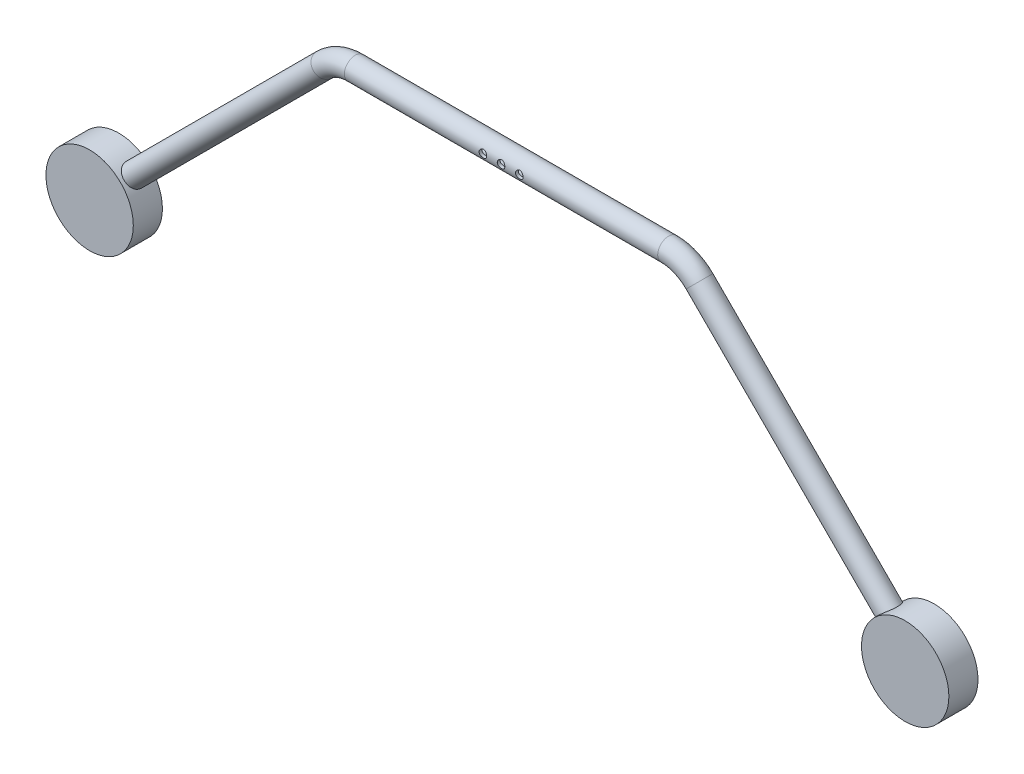
from build123d import *

# Parameters (mm, degrees)
SKETCH1_R                     = 38.1
BOSS_EXTRUDE1_DEPTH           = 25.4
BOSS_EXTRUDE1_2_DEPTH         = 25.4
SWEEP1_PROFILE_R              = 9.525
SHELL1_T                      = -2.54
M6_CLEARANCE_HOLE1_AT_2_COUNT = 2
M6_CLEARANCE_HOLE1_AT_2_PITCH = 31.75


with BuildPart() as part:
    # Sketch1 → Boss-Extrude1 (new body)
    with BuildSketch(Plane.XY):
        with Locations((-355.6, -203.2)):
            Circle(SKETCH1_R)
    extrude(amount=BOSS_EXTRUDE1_DEPTH)


with BuildPart() as body_2:
    # Sketch1 → Boss-Extrude1 2 (new body)
    with BuildSketch(Plane.XY):
        with Locations((355.6, -203.2)):
            Circle(SKETCH1_R)
    extrude(amount=BOSS_EXTRUDE1_2_DEPTH)


with BuildPart() as body_3:
    # Sweep1: sweep along a path in Sketch4
    with BuildLine(Plane.XY.offset(12.7)) as sweep1_path:
        Line((-355.6, -203.2), (-163.559231637, -11.159231637))
        ThreePointArc((-163.559231637, -11.159231637), (-151.198702047, -2.900189811), (-136.618463274, 0))
        Line((-136.618463274, 0), (136.618463274, 0))
        ThreePointArc((136.618463274, 0), (151.198702047, -2.900189811), (163.559231637, -11.159231637))
        Line((163.559231637, -11.159231637), (355.6, -203.2))
    # Sweep1 profile (on start of the path) → Sweep1 (sweep)
    with BuildSketch(Plane(origin=(-355.6, -203.2, 12.7), x_dir=(0.707106781, -0.707106781, 0), z_dir=(0.707106781, 0.707106781, 0))):
        Circle(SWEEP1_PROFILE_R)
    sweep(path=sweep1_path.line)

    # Shell1
    shell1_openings = [body_3.faces().sort_by_distance(p)[0] for p in [
        (348.864807909, -209.935192091, 12.7),
        (-348.864807909, -209.935192091, 12.7),
    ]]
    offset(amount=SHELL1_T, openings=shell1_openings, kind=Kind.INTERSECTION)

    # Sketch49 → M6 Clearance Hole1 (revolve, cut)
    with BuildSketch(Plane(origin=(-15.875, 0, 22.225), x_dir=(0, -1, 0), z_dir=(1, 0, 0))):
        Polygon((0, 0), (0, 22.225), (3.3, 22.225), (3.3, 0.025), (3.325, 0), align=None)
    m6_clearance_hole1 = revolve(axis=Axis((-15.875, 0, 28.575), (0, 0, -1)), mode=Mode.SUBTRACT)

    # M6 Clearance Hole1 at 2: M6 Clearance Hole1 ×2
    with Locations(*[(i * M6_CLEARANCE_HOLE1_AT_2_PITCH, 0, 0) for i in range(1, M6_CLEARANCE_HOLE1_AT_2_COUNT)]):
        add(m6_clearance_hole1, mode=Mode.SUBTRACT)

    # Sketch51 → M6 Clearance Hole2 (revolve, cut)
    with BuildSketch(Plane(origin=(0, 0, 22.225), x_dir=(0, -1, 0), z_dir=(1, 0, 0))):
        Polygon((0, 0), (0, 22.225), (3.3, 22.225), (3.3, 0.025), (3.325, 0), align=None)
    revolve(axis=Axis((0, 0, 28.575), (0, 0, -1)), mode=Mode.SUBTRACT)


solid = Compound([part.part, body_2.part, body_3.part])
